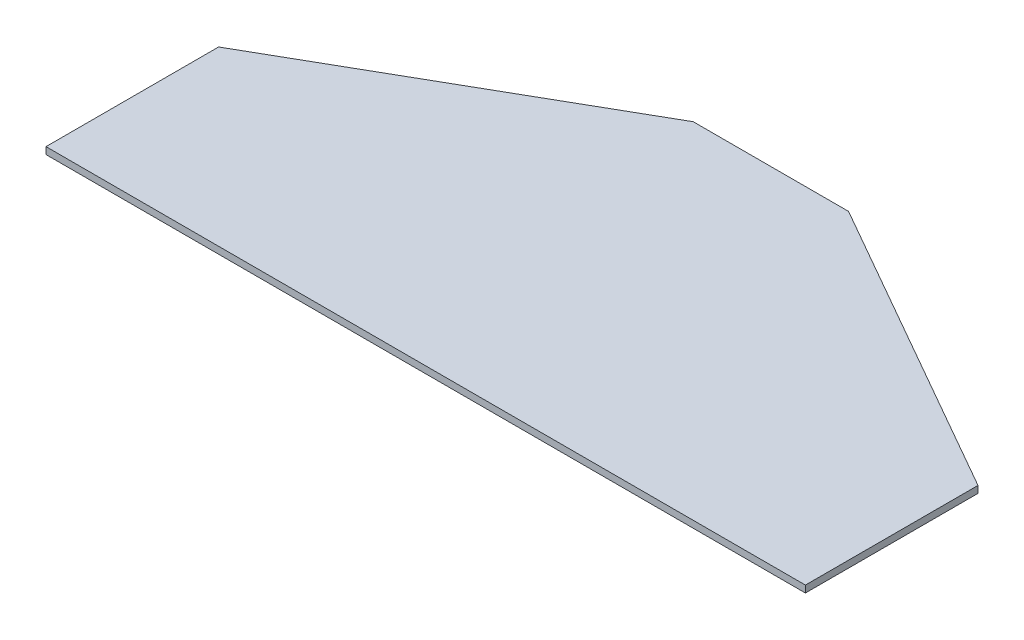
from build123d import *

# Parameters (mm, degrees)
BOSS_EXTRUDE1_DEPTH = 2.54


with BuildPart() as part:
    # Sketch1 → Boss-Extrude1 (new body)
    with BuildSketch(Plane(origin=(0, 0, 0), x_dir=(1, 0, 0), z_dir=(0, 1, 0))):
        Polygon((-139.7, 0), (139.7, 0), (139.7, 63.5), (28.575, 127), (-28.575, 127), (-139.7, 63.5), align=None)
    extrude(amount=BOSS_EXTRUDE1_DEPTH)


solid = part.part
